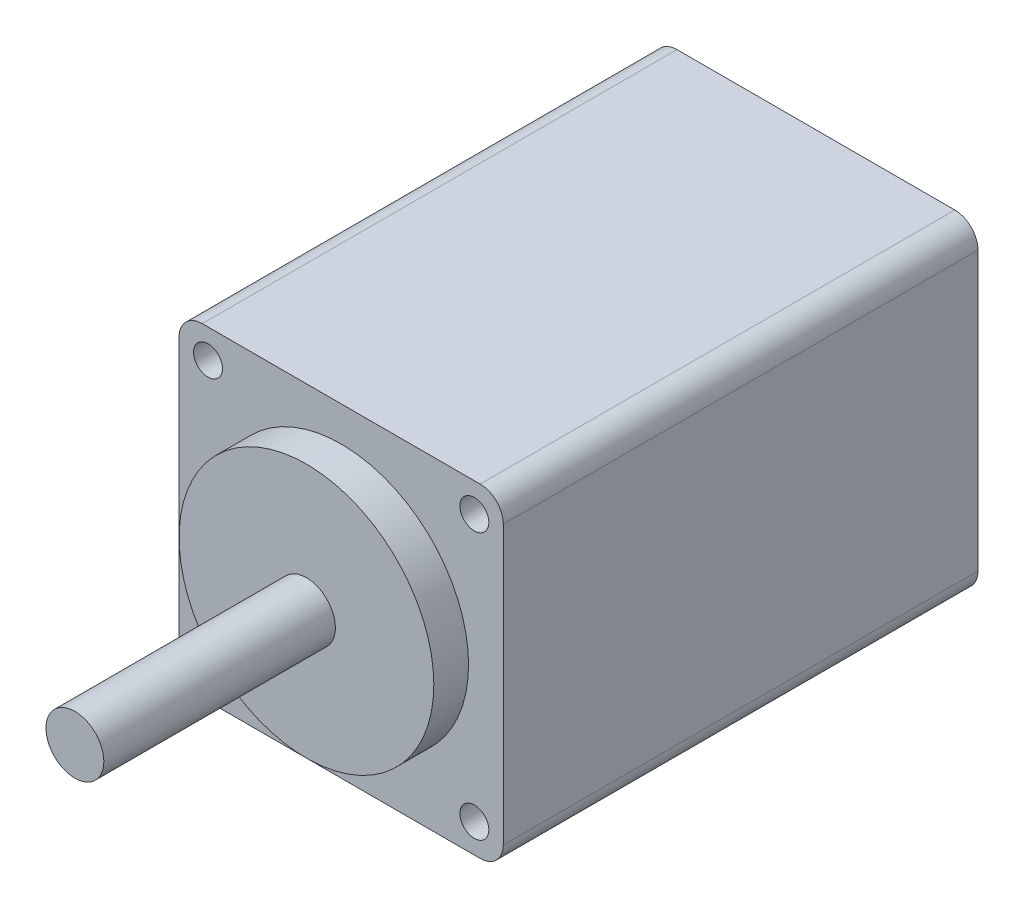
from build123d import *

# Parameters (mm, degrees)
SKETCH_1_W      = 28
SKETCH_1_H      = 28
SKETCH_1_R      = 1.25
EXTRUDE_1_DEPTH = 41
SKETCH_2_R      = 11
EXTRUDE_2_DEPTH = 3
SKETCH_3_R      = 2.5
EXTRUDE_3_DEPTH = 20
FILLET_1_R      = 2


with BuildPart() as part:
    # 草图1 → 凸台-拉伸1 (new body)
    with BuildSketch(Plane.XY):
        Rectangle(SKETCH_1_W, SKETCH_1_H)
        with Locations((-11.5, 11.5)):
            Circle(SKETCH_1_R, mode=Mode.SUBTRACT)
        with Locations((11.5, 11.5)):
            Circle(SKETCH_1_R, mode=Mode.SUBTRACT)
        with Locations((11.5, -11.5)):
            Circle(SKETCH_1_R, mode=Mode.SUBTRACT)
        with Locations((-11.5, -11.5)):
            Circle(SKETCH_1_R, mode=Mode.SUBTRACT)
    extrude(amount=EXTRUDE_1_DEPTH)

    # 草图2 → 凸台-拉伸2 (add)
    with BuildSketch(Plane.XY.offset(41)):
        Circle(SKETCH_2_R)
    extrude(amount=EXTRUDE_2_DEPTH)

    # 草图3 → 凸台-拉伸3 (add)
    with BuildSketch(Plane.XY.offset(44)):
        Circle(SKETCH_3_R)
    extrude(amount=EXTRUDE_3_DEPTH)

    # 圆角1
    fillet_1_edges = [part.edges().sort_by_distance(p)[0] for p in [
        (14, -14, 20.5),
        (-14, -14, 20.5),
        (-14, 14, 20.5),
        (14, 14, 20.5),
    ]]
    fillet(fillet_1_edges, radius=FILLET_1_R)


solid = part.part
